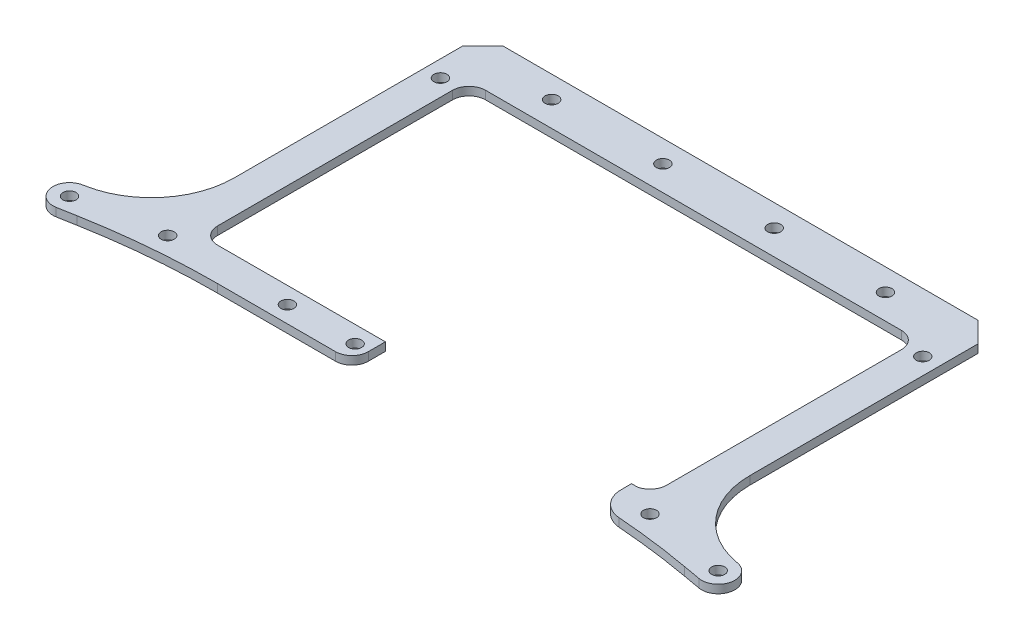
from build123d import *

# Parameters (mm, degrees)
SKETCH1_R           = 2.4892
BOSS_EXTRUDE1_DEPTH = 3.175


with BuildPart() as part:
    # Sketch1 → Boss-Extrude1 (new body)
    with BuildSketch(Plane(origin=(0, 0, 0), x_dir=(1, 0, 0), z_dir=(0, 1, 0))):
        with BuildLine():
            Line((-32.037640644, 123.979709158), (-111.412640644, 123.979709158))
            ThreePointArc((-111.412640644, 123.979709158), (-115.902768704, 122.119837219), (-117.762640644, 117.629709158))
            Line((-117.762640644, 117.629709158), (-117.762640644, 27.967709158))
            ThreePointArc((-117.762640644, 27.967709158), (-115.902768704, 23.477581098), (-111.412640644, 21.617709158))
            Line((-111.412640644, 21.617709158), (-47.412584086, 21.687857346))
            Line((-47.412584086, 21.687857346), (-47.412584086, 15.168903158))
            ThreePointArc((-47.412584086, 15.168903158), (-49.243516418, 10.748641491), (-53.663778086, 8.917709158))
            Line((-53.663778086, 8.917709158), (-98.720178026, 8.917709158))
            ThreePointArc((-98.720178026, 8.917709158), (-123.447337141, 7.816048009), (-147.978557367, 4.519794164))
            Line((-147.978557367, 4.519794164), (-154.737719104, 3.303145051))
            ThreePointArc((-154.737719104, 3.303145051), (-162.112204751, 8.427787619), (-156.987562183, 15.802273266))
            Line((-156.987562183, 15.802273266), (-156.510910789, 15.888070517))
            ThreePointArc((-156.510910789, 15.888070517), (-137.832620256, 26.738584362), (-130.462640644, 47.043647486))
            Line((-130.462640644, 47.043647486), (-130.462640644, 134.142309925))
            Line((-130.462640644, 134.142309925), (-122.659506644, 141.945443925))
            Line((-122.659506644, 141.945443925), (58.584225356, 141.945443925))
            Line((58.584225356, 141.945443925), (66.387359356, 134.142309925))
            Line((66.387359356, 134.142309925), (66.387359356, 47.043647486))
            ThreePointArc((66.387359356, 47.043647486), (73.757338969, 26.738584362), (92.435629502, 15.888070517))
            Line((92.435629502, 15.888070517), (92.912280896, 15.802273266))
            ThreePointArc((92.912280896, 15.802273266), (98.036923464, 8.427787619), (90.662437817, 3.303145051))
            Line((90.662437817, 3.303145051), (83.90327608, 4.519794164))
            ThreePointArc((83.90327608, 4.519794164), (69.690534676, 6.700322348), (55.384073682, 8.143199745))
            ThreePointArc((55.384073682, 8.143199745), (49.05429115, 11.190619944), (46.487475356, 17.730067432))
            Line((46.487475356, 17.730067432), (46.487475356, 21.600342717))
            ThreePointArc((46.487475356, 21.600342717), (46.487422167, 21.617708833), (46.487262601, 21.635074297))
            Line((46.487262601, 21.635074297), (46.485354971, 21.790775541))
            Line((46.485354971, 21.790775541), (48.820465356, 21.793334972))
            ThreePointArc((48.820465356, 21.793334972), (52.324353596, 24.036756545), (53.687359356, 27.967709158))
            Line((53.687359356, 27.967709158), (53.687359356, 117.629709158))
            ThreePointArc((53.687359356, 117.629709158), (51.827487417, 122.119837219), (47.337359356, 123.979709158))
            Line((47.337359356, 123.979709158), (-32.037640644, 123.979709158))
        make_face()
        with Locations((60.037359356, 119.407709158)):
            Circle(SKETCH1_R, mode=Mode.SUBTRACT)
        with Locations((-52.542234775, 15.267709158)):
            Circle(SKETCH1_R, mode=Mode.SUBTRACT)
        with Locations((-78.392640644, 15.267709158)):
            Circle(SKETCH1_R, mode=Mode.SUBTRACT)
        with Locations((-10.796890644, 133.504709158)):
            Circle(SKETCH1_R, mode=Mode.SUBTRACT)
        with Locations((31.684609356, 133.504709158)):
            Circle(SKETCH1_R, mode=Mode.SUBTRACT)
        with Locations((91.787359356, 9.552709158)):
            Circle(SKETCH1_R, mode=Mode.SUBTRACT)
        with Locations((-53.278390644, 133.504709158)):
            Circle(SKETCH1_R, mode=Mode.SUBTRACT)
        with Locations((-95.759890644, 133.504709158)):
            Circle(SKETCH1_R, mode=Mode.SUBTRACT)
        with Locations((-124.112640644, 15.267709158)):
            Circle(SKETCH1_R, mode=Mode.SUBTRACT)
        with Locations((-155.862640644, 9.552709158)):
            Circle(SKETCH1_R, mode=Mode.SUBTRACT)
        with Locations((-124.112640644, 119.407709158)):
            Circle(SKETCH1_R, mode=Mode.SUBTRACT)
        with Locations((60.037359356, 15.267709158)):
            Circle(SKETCH1_R, mode=Mode.SUBTRACT)
    extrude(amount=BOSS_EXTRUDE1_DEPTH)


solid = part.part
